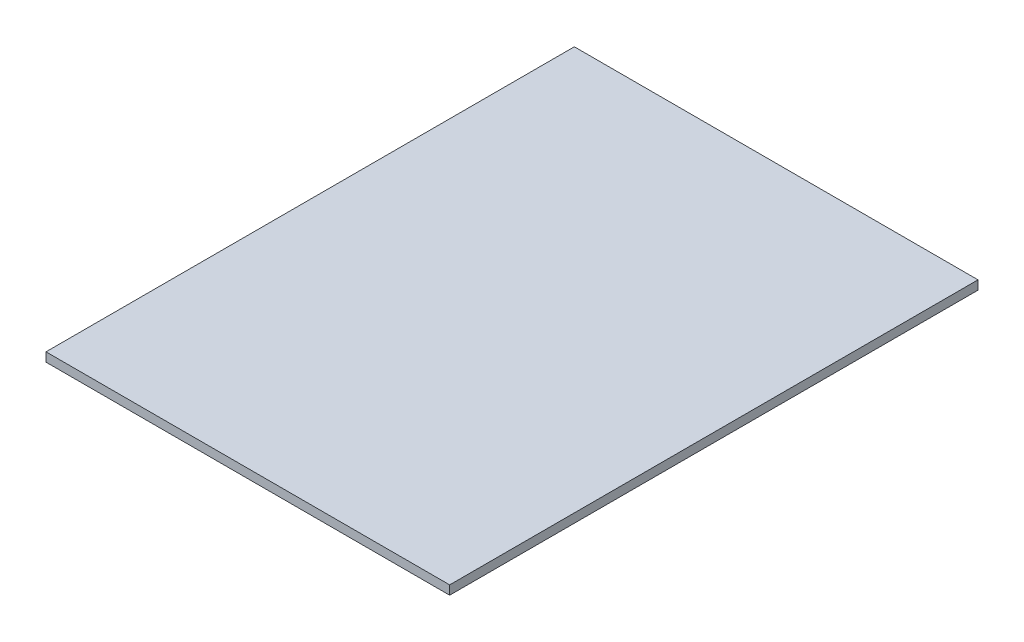
from build123d import *

# Parameters (mm, degrees)
SKETCH1_W           = 54
SKETCH1_H           = 70.68
BOSS_EXTRUDE1_DEPTH = 1.2


with BuildPart() as part:
    # Sketch1 → Boss-Extrude1 (new body)
    with BuildSketch(Plane(origin=(0, 0, 0), x_dir=(1, 0, 0), z_dir=(0, 1, 0))):
        with Locations((27, 35.34)):
            Rectangle(SKETCH1_W, SKETCH1_H)
    extrude(amount=BOSS_EXTRUDE1_DEPTH)


solid = part.part
